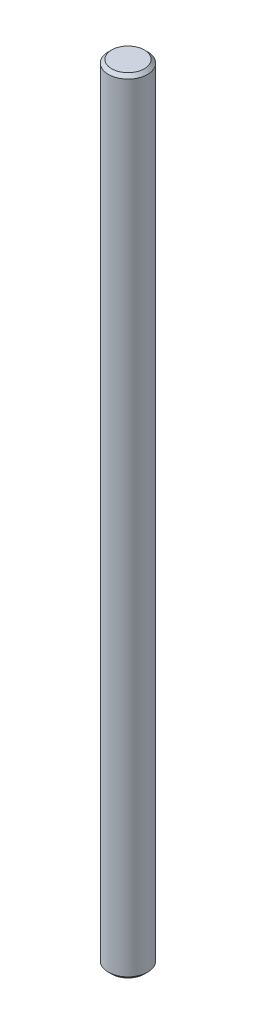
from build123d import *

# Parameters (mm, degrees)
SKETCH1_R      = 6
EXTRUDE1_DEPTH = 240
CHAMFER1_SIZE  = 1


with BuildPart() as part:
    # Sketch1 → Extrude1 (new body)
    with BuildSketch(Plane(origin=(0, 0, 0), x_dir=(1, 0, 0), z_dir=(0, 1, 0))):
        with Locations((0, 0.010418865)):
            Circle(SKETCH1_R)
    extrude(amount=EXTRUDE1_DEPTH)

    # Chamfer1
    chamfer1_edges = [part.edges().sort_by_distance(p)[0] for p in [
        (-6, 0, -0.010418865),
        (-6, 240, -0.010418865),
    ]]
    chamfer(chamfer1_edges, length=CHAMFER1_SIZE)


solid = part.part
